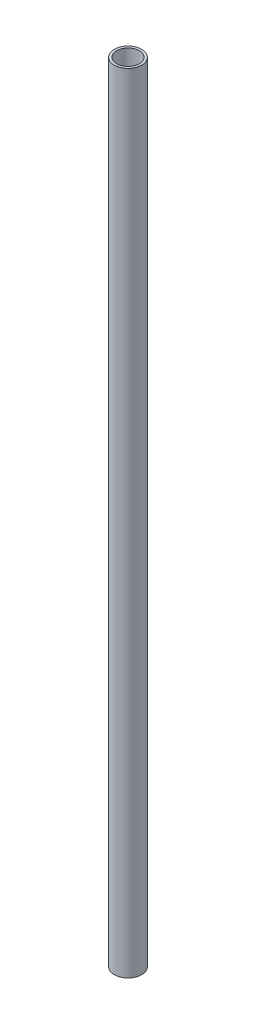
from build123d import *

# Parameters (mm, degrees)
SKETCH1_R           = 9.525
SKETCH1_R_2         = 7.874
BOSS_EXTRUDE1_DEPTH = 546.1
SKETCH2_R           = 1.5875
CUT_EXTRUDE1_DEPTH  = 279.527


with BuildPart() as part:
    # Sketch1 → Boss-Extrude1 (new body)
    with BuildSketch(Plane(origin=(0, 0, 0), x_dir=(1, 0, 0), z_dir=(0, 1, 0))):
        Circle(SKETCH1_R)
        Circle(SKETCH1_R_2, mode=Mode.SUBTRACT)
    extrude(amount=BOSS_EXTRUDE1_DEPTH)

    # Sketch2 → Cut-Extrude1 (cut)
    with BuildSketch(Plane(origin=(603.369857171, -776.603382372, -147.728206949), x_dir=(0.97105263, 0, 0.238865629), z_dir=(-0.238865629, 0, 0.97105263))):
        with Locations((-550.61669584, 782.953382372)):
            Circle(SKETCH2_R)
    extrude(amount=CUT_EXTRUDE1_DEPTH, mode=Mode.SUBTRACT)


solid = part.part
